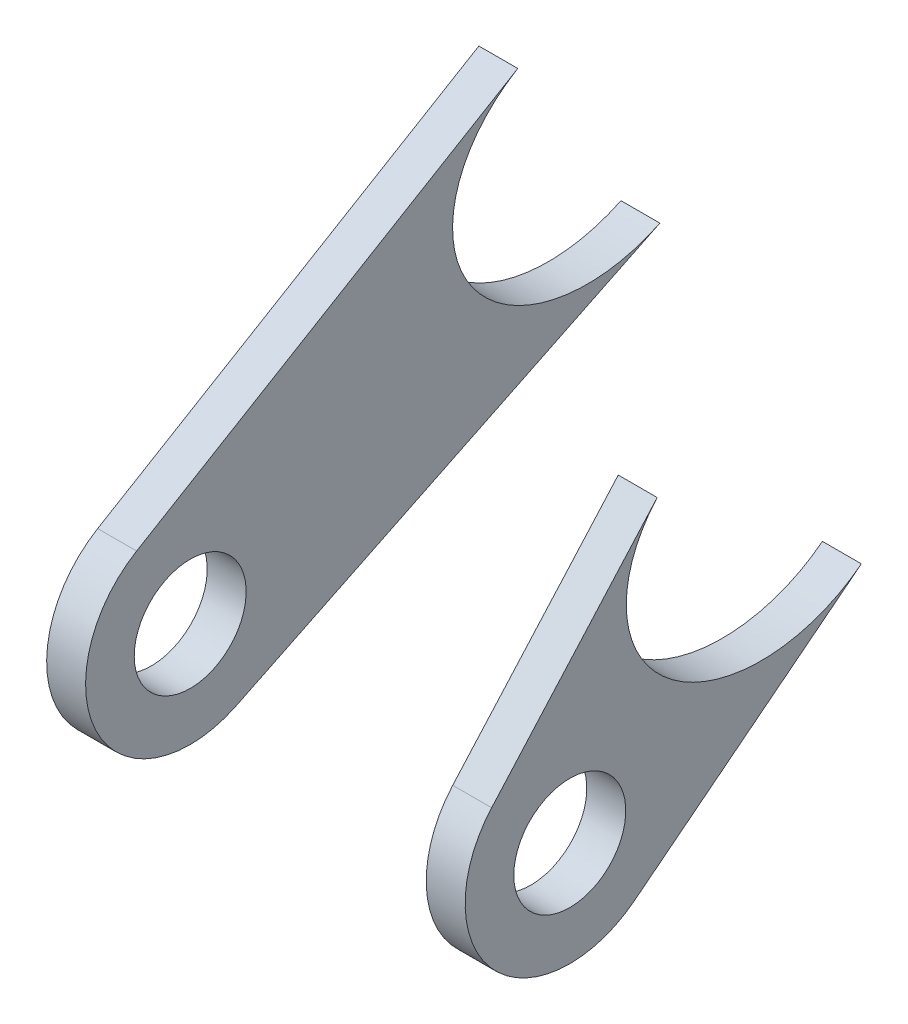
from build123d import *

# Parameters (mm, degrees)
SZKIC1_R                    = 5.75
DODANIE_WYCI_GNI_CIE1_DEPTH = 4
SZKIC2_R                    = 5.75
DODANIE_WYCI_GNI_CIE2_DEPTH = 4


with BuildPart() as part:
    # Szkic1 → Dodanie-wyciągnięcie1 (new body)
    with BuildSketch(Plane(origin=(-28.685367511, 1.43e-07, -7.33e-07), x_dir=(-2.6e-08, 0, 1), z_dir=(-1, 5e-09, -2.6e-08))):
        with BuildLine():
            Line((465.183030948, -257.038339395), (508.736535292, -278.232362129))
            ThreePointArc((508.736535292, -278.232362129), (522.898407751, -273.675636359), (518.946424449, -259.333244325))
            Line((518.946424449, -259.333244325), (479.782824247, -235.97770815))
            add(Edge.make_bspline(
                [(479.782824247, -235.97770815), (485.271231223, -239.250764943), (487.05070972, -244.206726363), (486.344854352, -248.538774469), (485.058364408, -256.434352762), (476.490731879, -262.540897093), (465.183030948, -257.038339395)],
                knots=[0.305089223, 0.305089223, 0.305089223, 0.305089223, 0.5, 0.5, 0.5, 0.792676252, 0.792676252, 0.792676252, 0.792676252], degree=3, weights=[0.52427858, 0.581545157, 0.740118964, 1, 0.609764997, 0.44795503, 0.5145701]))
        make_face()
        with Locations((513.440338286, -268.566094111)):
            Circle(SZKIC1_R, mode=Mode.SUBTRACT)
    extrude(amount=DODANIE_WYCI_GNI_CIE1_DEPTH)


with BuildPart() as body_2:
    # Szkic2 → Dodanie-wyciągnięcie2 (new body)
    with BuildSketch(Plane(origin=(6.314632489, -3.1e-08, 1.61e-07), x_dir=(-2.6e-08, 0, 1), z_dir=(-1, 5e-09, -2.6e-08))):
        with BuildLine():
            Line((483.483036976, -258.705084661), (506.800003645, -277.019995923))
            ThreePointArc((506.800003645, -277.019995923), (521.27263456, -275.92935664), (521.468609055, -261.417012459))
            Line((521.468609055, -261.417012459), (504.458992944, -242.315565525))
            add(Edge.make_bspline(
                [(504.458992944, -242.315565525), (507.216307395, -245.411972599), (507.999423061, -248.899340162), (507.496618946, -251.985201245), (505.969078098, -261.360181924), (494.952781909, -267.71429086), (483.483036976, -258.705084661)],
                knots=[0.349940267, 0.349940267, 0.349940267, 0.349940267, 0.5, 0.5, 0.5, 0.823836763, 0.823836763, 0.823836763, 0.823836763], degree=3, weights=[0.579904455, 0.659888507, 0.799920356, 1, 0.568217649, 0.416089296, 0.543614941]))
        make_face()
        with Locations((513.440338286, -268.566094111)):
            Circle(SZKIC2_R, mode=Mode.SUBTRACT)
    extrude(amount=-DODANIE_WYCI_GNI_CIE2_DEPTH)


solid = Compound([part.part, body_2.part])
